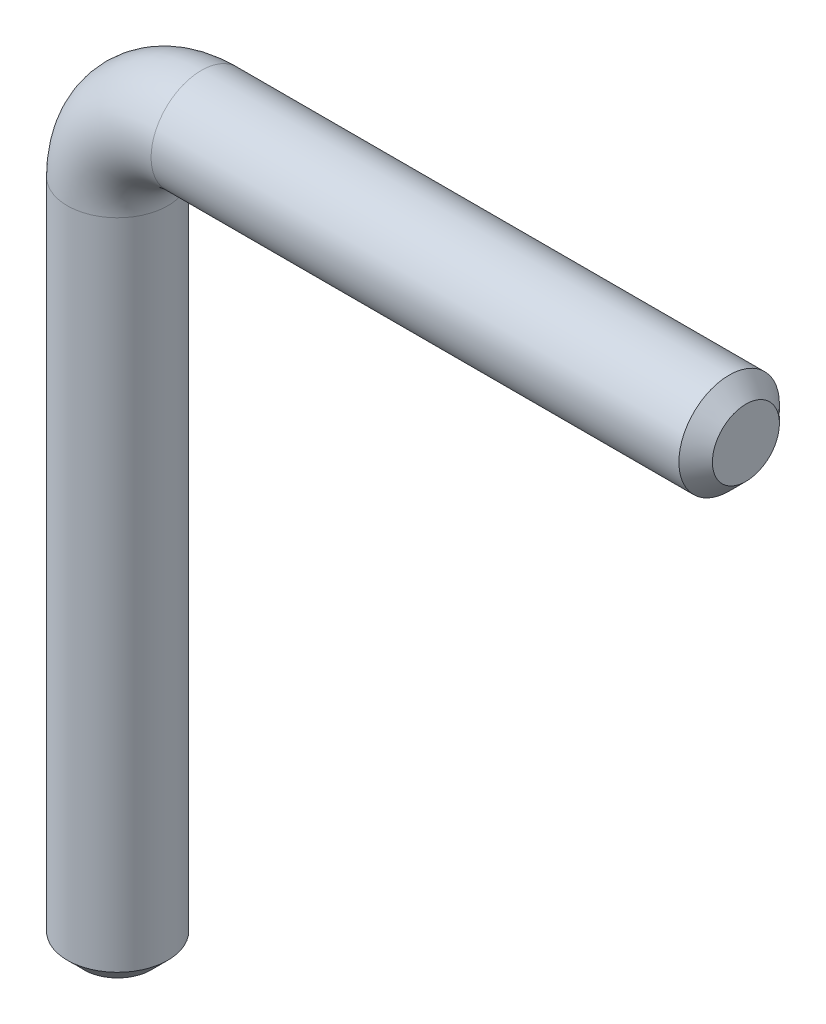
from build123d import *

# Parameters (mm, degrees)
SWEEP1_PROFILE_R = 6
CHAMFER1_SIZE    = 2


with BuildPart() as part:
    # Sweep1: sweep along a path in Sketch1
    with BuildLine(Plane.XY) as sweep1_path:
        Line((75, 90), (10, 90))
        ThreePointArc((10, 90), (2.928932188, 87.071067812), (0, 80))
        Line((0, 80), (0, 0))
    # Sweep1 profile (on start of the path) → Sweep1 (sweep)
    with BuildSketch(Plane(origin=(75, 90, 0), x_dir=(0, -1, 0), z_dir=(-1, 0, 0))):
        Circle(SWEEP1_PROFILE_R)
    sweep(path=sweep1_path.line)

    # Chamfer1
    chamfer1_edges = [part.edges().sort_by_distance(p)[0] for p in [
        (-6, 0, 0),
        (75, 96, 0),
    ]]
    chamfer(chamfer1_edges, length=CHAMFER1_SIZE)


solid = part.part
